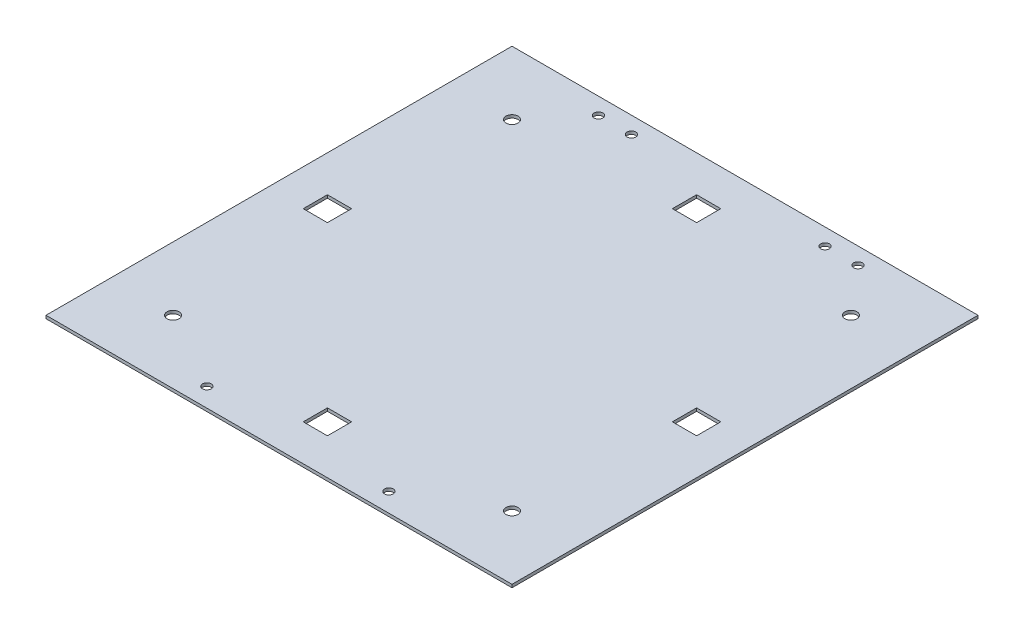
from build123d import *

# Parameters (mm, degrees)
SKETCH1_W               = 244.475
SKETCH1_H               = 244.475
MAIN_BODY_DEPTH         = 1.5875
SKETCH2_R               = 2.286
HINGES_LOCK_HOLES_DEPTH = 2.5875
SKETCH3_R               = 3.175
THREAD_HOLES_DEPTH      = 2.5875
SKETCH4_W               = 12.7
SKETCH4_H               = 12.7
LED_HOLES_DEPTH         = 2.5875


with BuildPart() as part:
    # Sketch1 → Main Body (new body)
    with BuildSketch(Plane(origin=(0, 0, 0), x_dir=(1, 0, 0), z_dir=(0, 1, 0))):
        with Locations((122.2375, 122.2375)):
            Rectangle(SKETCH1_W, SKETCH1_H)
    extrude(amount=MAIN_BODY_DEPTH)

    # Sketch2 → Hinges/Lock Holes (cut, through all)
    with BuildSketch(Plane(origin=(0, 1.5875, 0), x_dir=(1, 0, 0), z_dir=(0, 1, 0))):
        with Locations((54.1655, 235.6866)):
            Circle(SKETCH2_R)
        with Locations((71.4375, 235.6866)):
            Circle(SKETCH2_R)
        with Locations((173.0375, 235.6866)):
            Circle(SKETCH2_R)
        with Locations((190.3095, 235.6866)):
            Circle(SKETCH2_R)
        with Locations((74.4855, 9.906)):
            Circle(SKETCH2_R)
        with Locations((169.9895, 9.906)):
            Circle(SKETCH2_R)
    extrude(amount=-HINGES_LOCK_HOLES_DEPTH, mode=Mode.SUBTRACT)

    # Sketch3 → Thread Holes (cut, through all)
    with BuildSketch(Plane(origin=(0, 1.5875, 0), x_dir=(1, 0, 0), z_dir=(0, 1, 0))):
        with Locations((211.1375, 33.3375)):
            Circle(SKETCH3_R)
        with Locations((33.3375, 211.1375)):
            Circle(SKETCH3_R)
        with Locations((211.1375, 211.1375)):
            Circle(SKETCH3_R)
        with Locations((33.3375, 33.3375)):
            Circle(SKETCH3_R)
    extrude(amount=-THREAD_HOLES_DEPTH, mode=Mode.SUBTRACT)

    # Sketch4 → LED Holes (cut, through all)
    with BuildSketch(Plane(origin=(0, 1.5875, 0), x_dir=(1, 0, 0), z_dir=(0, 1, 0))):
        with Locations((122.2375, 25.4)):
            Rectangle(SKETCH4_W, SKETCH4_H)
        with Locations((25.4, 122.2375)):
            Rectangle(SKETCH4_W, SKETCH4_H)
        with Locations((122.2375, 219.075)):
            Rectangle(SKETCH4_W, SKETCH4_H)
        with Locations((219.075, 122.2375)):
            Rectangle(SKETCH4_W, SKETCH4_H)
    extrude(amount=-LED_HOLES_DEPTH, mode=Mode.SUBTRACT)


solid = part.part
